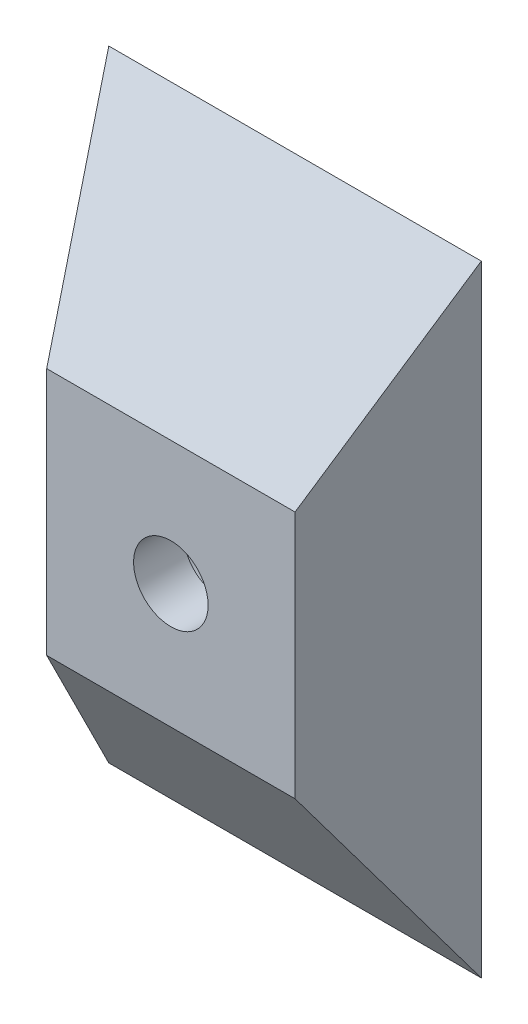
from build123d import *

# Parameters (mm, degrees)
CROQUIS1_W            = 15
CROQUIS1_H            = 25
CROQUIS9_W            = 10
CROQUIS9_H            = 10
CROQUIS10_R           = 1.5
CORTAR_EXTRUIR1_DEPTH = 5
CROQUIS11_R           = 2.5
CORTAR_EXTRUIR2_DEPTH = 3


with BuildPart() as part:
    # Croquis1 → Recubrir1 section 0
    with BuildSketch(Plane.XY):
        Rectangle(CROQUIS1_W, CROQUIS1_H)
    # Croquis9 → Recubrir1 section 1
    with BuildSketch(Plane.XY.offset(5)):
        Rectangle(CROQUIS9_W, CROQUIS9_H)
    loft()

    # Croquis10 → Cortar-Extruir1 (cut)
    with BuildSketch(Plane.XY.offset(5)):
        Circle(CROQUIS10_R)
    extrude(amount=-CORTAR_EXTRUIR1_DEPTH, mode=Mode.SUBTRACT)

    # Croquis11 → Cortar-Extruir2 (cut)
    with BuildSketch(Plane(origin=(0, 0, 0), x_dir=(-1, 0, 0), z_dir=(0, 0, -1))):
        Circle(CROQUIS11_R)
    extrude(amount=-CORTAR_EXTRUIR2_DEPTH, mode=Mode.SUBTRACT)


solid = part.part
